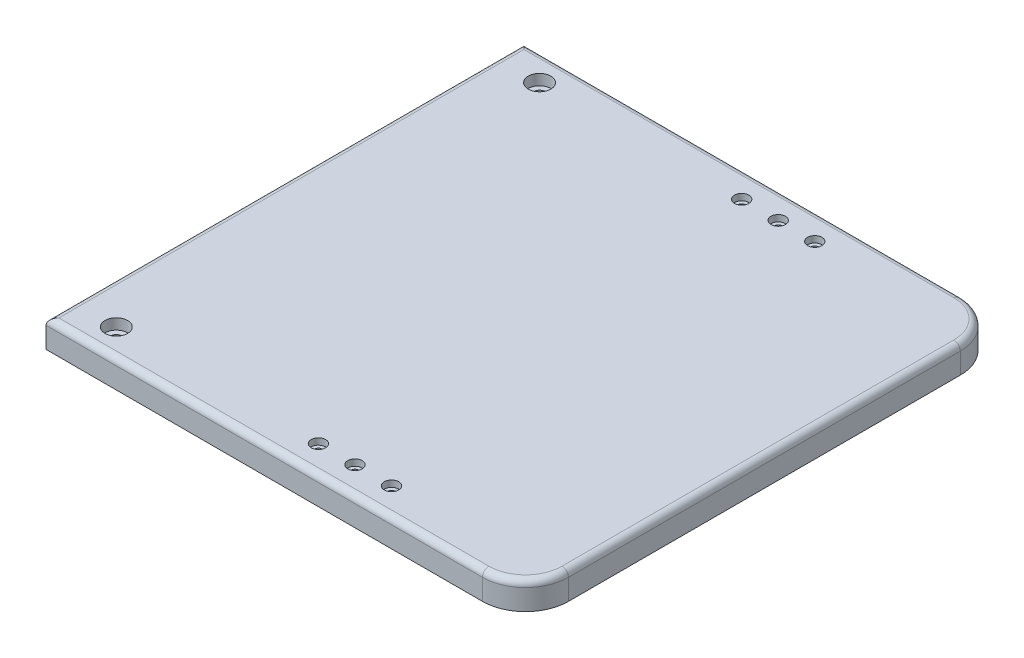
from build123d import *

# Parameters (mm, degrees)
SKETCH2_W                       = 223
SKETCH2_H                       = 222.25
BOSS_EXTRUDE1_DEPTH             = 12.7
FILLET6_R                       = 20
FILLET5_R                       = 3
CBORE_FOR_M3_SBHCS1_D           = 3.4
CBORE_FOR_M3_SBHCS1_DEPTH       = 12.7
CBORE_FOR_M3_SBHCS1_CBORE_D     = 6.7
CBORE_FOR_M3_SBHCS1_CBORE_DEPTH = 3
CBORE_FOR_M5_SBHCS1_D           = 5.5
CBORE_FOR_M5_SBHCS1_DEPTH       = 12.7
CBORE_FOR_M5_SBHCS1_CBORE_D     = 10.5
CBORE_FOR_M5_SBHCS1_CBORE_DEPTH = 5
SKETCH9_R                       = 6.5
CUT_EXTRUDE1_DEPTH              = 2


with BuildPart() as part:
    # Sketch2 → Boss-Extrude1 (new body)
    with BuildSketch(Plane(origin=(0, 0, 0), x_dir=(1, 0, 0), z_dir=(0, 1, 0))):
        Rectangle(SKETCH2_W, SKETCH2_H)
    extrude(amount=BOSS_EXTRUDE1_DEPTH)

    # Fillet6
    fillet6_edges = [part.edges().sort_by_distance(p)[0] for p in [
        (111.5, 6.35, 111.125),
        (111.5, 6.35, -111.125),
    ]]
    fillet(fillet6_edges, radius=FILLET6_R)

    # Fillet5
    fillet5_edges = [part.edges().sort_by_distance(p)[0] for p in [
        (-111.5, 12.7, 0),
        (-10, 12.7, -111.125),
        (-10, 12.7, 111.125),
        (111.5, 12.7, 0),
        (105.642135624, 12.7, 105.267135624),
        (105.642135624, 12.7, -105.267135624),
    ]]
    fillet(fillet5_edges, radius=FILLET5_R)

    # CBORE for M3 SBHCS1
    with Locations(Plane(origin=(0, 12.7, 0), x_dir=(1, 0, 0), z_dir=(0, 1, 0))):
        with Locations((36.5, -98.425), (36.5, 98.425), (19.5, -98.425), (19.5, 98.425), (2.5, -98.425), (2.5, 98.425)):
            CounterBoreHole(CBORE_FOR_M3_SBHCS1_D / 2, CBORE_FOR_M3_SBHCS1_CBORE_D / 2, CBORE_FOR_M3_SBHCS1_CBORE_DEPTH, depth=CBORE_FOR_M3_SBHCS1_DEPTH)

    # CBORE for M5 SBHCS1
    with Locations(Plane(origin=(0, 12.7, 0), x_dir=(1, 0, 0), z_dir=(0, 1, 0))):
        with Locations((-91.5, 98.425), (-91.5, -98.425)):
            CounterBoreHole(CBORE_FOR_M5_SBHCS1_D / 2, CBORE_FOR_M5_SBHCS1_CBORE_D / 2, CBORE_FOR_M5_SBHCS1_CBORE_DEPTH, depth=CBORE_FOR_M5_SBHCS1_DEPTH)

    # Sketch9 → Cut-Extrude1 (cut)
    with BuildSketch(Plane.XZ):
        with Locations((-91.5, 98.425)):
            Circle(SKETCH9_R)
        with Locations((-91.5, -98.425)):
            Circle(SKETCH9_R)
    extrude(amount=-CUT_EXTRUDE1_DEPTH, mode=Mode.SUBTRACT)


solid = part.part
